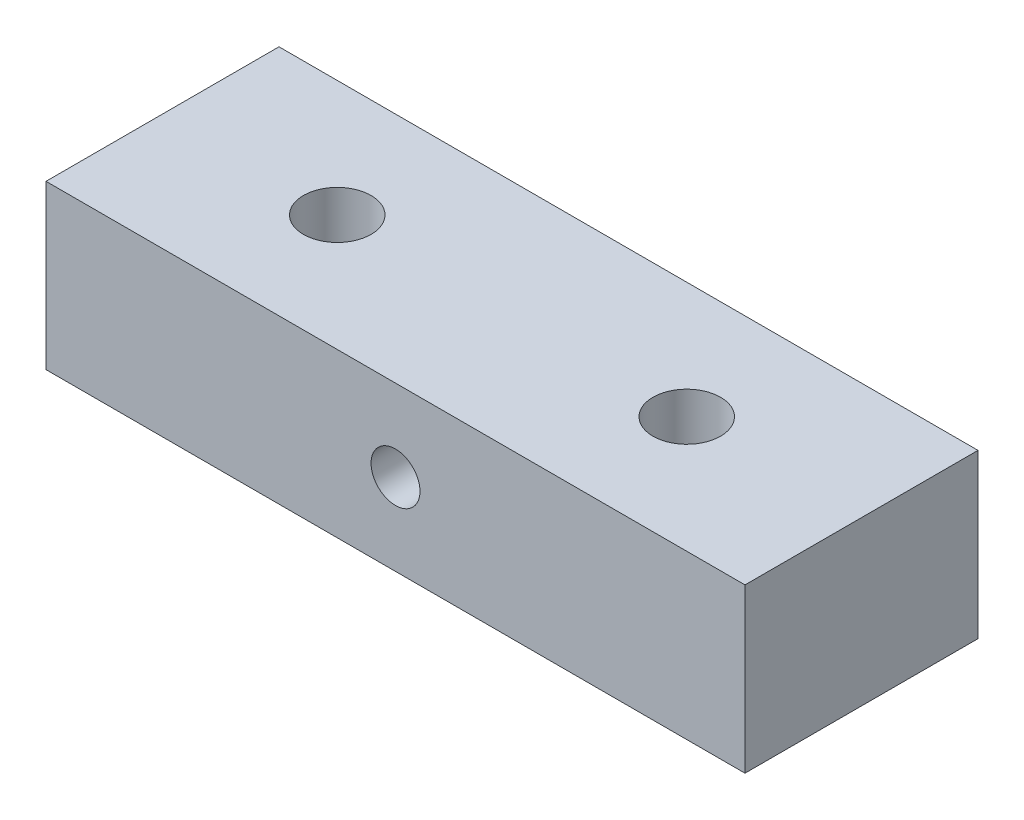
from build123d import *

# Parameters (mm, degrees)
SKETCH1_W           = 30
SKETCH1_H           = 7
BOSS_EXTRUDE1_DEPTH = 10
SKETCH2_R           = 1.05
CUT_EXTRUDE1_DEPTH  = 10
SKETCH3_R           = 1.45
CUT_EXTRUDE2_DEPTH  = 8


with BuildPart() as part:
    # Sketch1 → Boss-Extrude1 (new body)
    with BuildSketch(Plane.XY):
        with Locations((15, 3.5)):
            Rectangle(SKETCH1_W, SKETCH1_H)
    extrude(amount=BOSS_EXTRUDE1_DEPTH)

    # Sketch2 → Cut-Extrude1 (cut)
    with BuildSketch(Plane.XY.offset(10)):
        with Locations((15, 3.5)):
            Circle(SKETCH2_R)
    extrude(amount=-CUT_EXTRUDE1_DEPTH, mode=Mode.SUBTRACT)

    # Sketch3 → Cut-Extrude2 (cut, through all)
    with BuildSketch(Plane(origin=(0, 7, 0), x_dir=(1, 0, 0), z_dir=(0, 1, 0))):
        with Locations((7.5, -5)):
            Circle(SKETCH3_R)
        with Locations((22.5, -5)):
            Circle(SKETCH3_R)
    extrude(amount=-CUT_EXTRUDE2_DEPTH, mode=Mode.SUBTRACT)


solid = part.part
